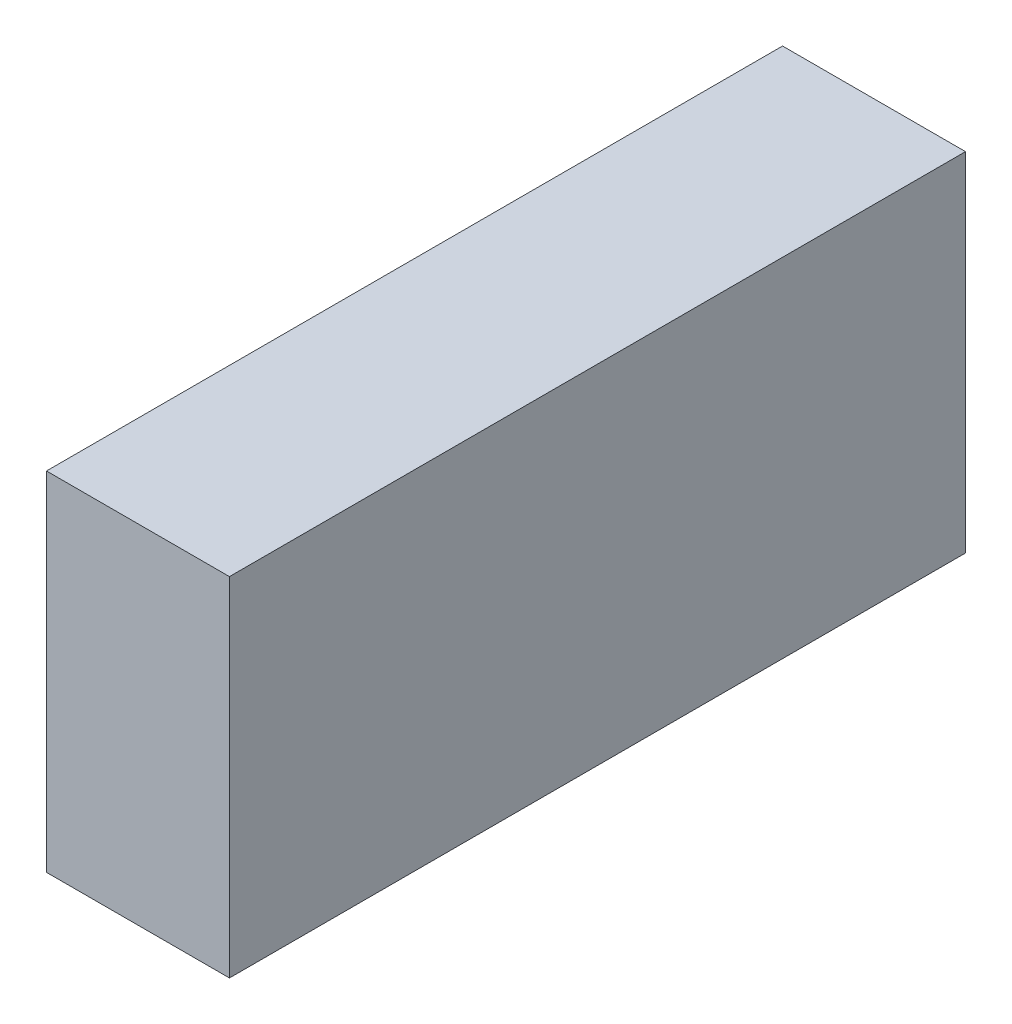
from build123d import *

# Parameters (mm, degrees)
SKETCH1_W      = 13
SKETCH1_H      = 24.7
EXTRUDE1_DEPTH = 52.3


with BuildPart() as part:
    # Sketch1 → Extrude1 (new body)
    with BuildSketch(Plane.XY):
        with Locations((-1.363907285, 3.020364238)):
            Rectangle(SKETCH1_W, SKETCH1_H)
    extrude(amount=EXTRUDE1_DEPTH)


solid = part.part
